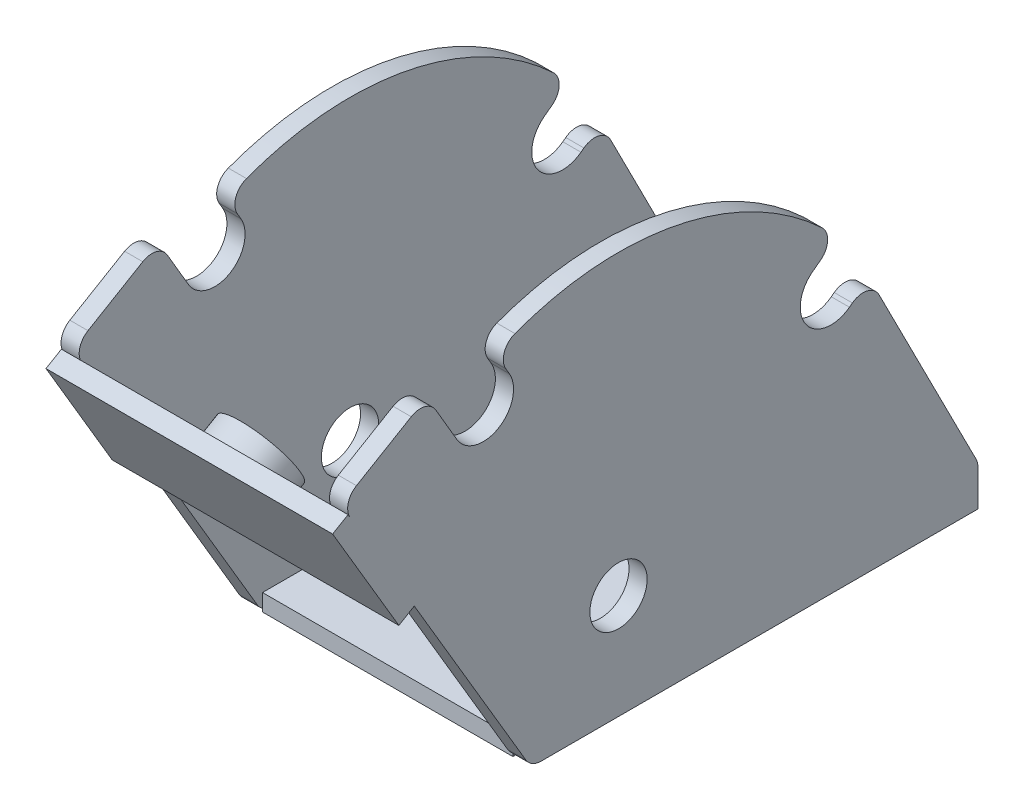
from build123d import *

# Parameters (mm, degrees)
SKETCH1_W           = 35.56
SKETCH1_H           = 63.5
SKETCH1_R           = 3.0734
BOSS_EXTRUDE1_DEPTH = 2.4003
SKETCH2_R           = 4.07035
BOSS_EXTRUDE2_DEPTH = 2.5781
SKETCH3_W           = 40.7162
SKETCH3_H           = 18.5166
BOSS_EXTRUDE3_DEPTH = 2.54
SKETCH4_R           = 5.5626
BOSS_EXTRUDE4_DEPTH = 3.7846


with BuildPart() as part:
    # Sketch1 → Boss-Extrude1 (new body)
    with BuildSketch(Plane(origin=(0, 0, 0), x_dir=(1, 0, 0), z_dir=(0, 1, 0))):
        Rectangle(SKETCH1_W, SKETCH1_H)
        with Locations((-11.0109, 22.225)):
            Circle(SKETCH1_R, mode=Mode.SUBTRACT)
        with Locations((-11.0109, -18.288)):
            Circle(SKETCH1_R, mode=Mode.SUBTRACT)
        with Locations((11.0109, -18.288)):
            Circle(SKETCH1_R, mode=Mode.SUBTRACT)
        with Locations((11.0109, 22.225)):
            Circle(SKETCH1_R, mode=Mode.SUBTRACT)
    extrude(amount=BOSS_EXTRUDE1_DEPTH)

    # Sketch2 → Boss-Extrude2 (add)
    with BuildSketch(Plane(origin=(17.78, 0, 0), x_dir=(0, 0, -1), z_dir=(1, 0, 0))):
        with BuildLine():
            Line((31.75, 0), (31.75, 5.119118053))
            ThreePointArc((31.75, 5.119118053), (31.680088236, 5.710949198), (31.474201493, 6.270200848))
            Line((31.474201493, 6.270200848), (17.693567666, 33.376966591))
            ThreePointArc((17.693567666, 33.376966591), (16.006303844, 34.699493087), (13.908046107, 34.259890987))
            Line((13.908046107, 34.259890987), (13.489778208, 33.947050723))
            ThreePointArc((13.489778208, 33.947050723), (7.374615324, 34.828872577), (8.256437178, 40.944035461))
            Line((8.256437178, 40.944035461), (9.378285973, 41.783113656))
            ThreePointArc((9.378285973, 41.783113656), (10.39301658, 43.675533493), (9.59524257, 45.66914521))
            ThreePointArc((9.59524257, 45.66914521), (-10.963994808, 56.277959645), (-34.028081087, 54.467680828))
            ThreePointArc((-34.028081087, 54.467680828), (-35.535691357, 52.940715566), (-35.336051172, 50.80421014))
            Line((-35.336051172, 50.80421014), (-34.816573654, 49.916114029))
            ThreePointArc((-34.816573654, 49.916114029), (-36.36360729, 44.008751256), (-42.270970063, 45.555784893))
            Line((-42.270970063, 45.555784893), (-45.277675805, 50.696033664))
            ThreePointArc((-45.277675805, 50.696033664), (-46.831353511, 51.871946179), (-48.760952094, 51.601143727))
            Line((-48.760952094, 51.601143727), (-56.540301411, 47.010806757))
            ThreePointArc((-56.540301411, 47.010806757), (-57.70907124, 45.457347112), (-57.437054463, 43.532440191))
            Line((-57.437054463, 43.532440191), (-32.487107654, 1.249193243))
            ThreePointArc((-32.487107654, 1.249193243), (-31.559101504, 0.334297259), (-30.299547846, 0))
            Line((-30.299547846, 0), (31.75, 0))
        make_face()
        with Locations((-19.316644044, 14.86535)):
            Circle(SKETCH2_R, mode=Mode.SUBTRACT)
    boss_extrude2 = extrude(amount=BOSS_EXTRUDE2_DEPTH)

    # Mirror1: Boss-Extrude2 across plane
    add(boss_extrude2.mirror(Plane.ZY))

    # Sketch3 → Boss-Extrude3 (add)
    with BuildSketch(Plane(origin=(0, -13.896244991, 23.550285021), x_dir=(1, 0, 0), z_dir=(0, -0.508191637, 0.861244019))):
        with Locations((0, 58.016828481)):
            Rectangle(SKETCH3_W, SKETCH3_H)
    extrude(amount=BOSS_EXTRUDE3_DEPTH)

    # Sketch4 → Boss-Extrude4 (add)
    with BuildSketch(Plane(origin=(0, -13.896244991, 23.550285021), x_dir=(-1, 0, 0), z_dir=(0, 0.508191637, -0.861244019))):
        with Locations((0, 58.016828481)):
            Circle(SKETCH4_R)
    extrude(amount=BOSS_EXTRUDE4_DEPTH)


solid = part.part
